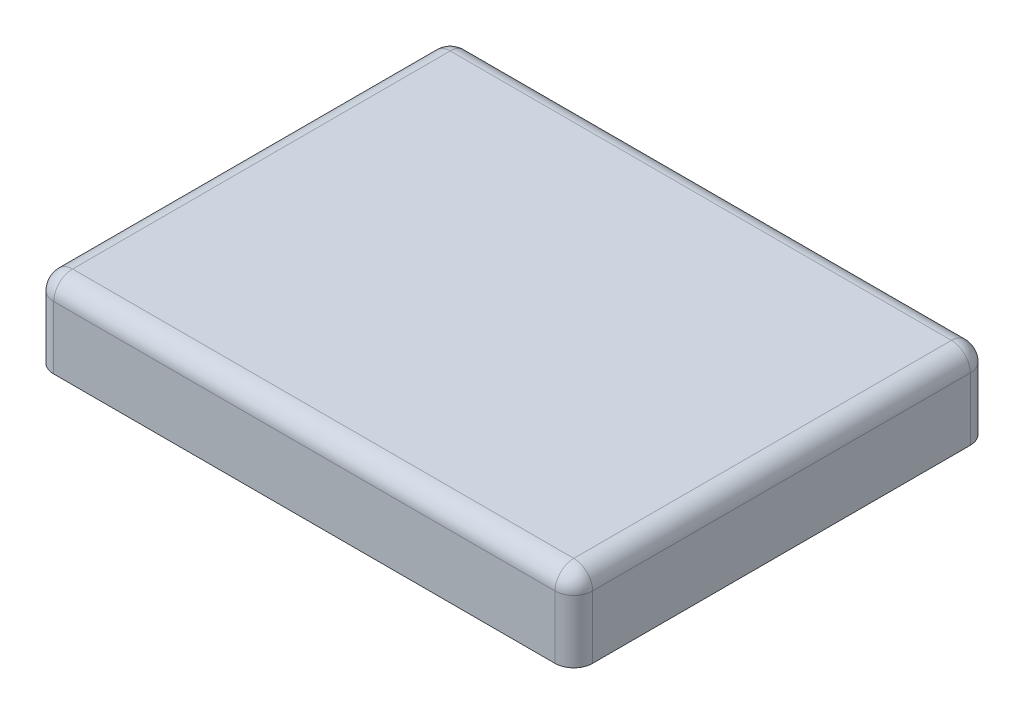
from build123d import *

# Parameters (mm, degrees)
SKETCH1_W           = 436.372
SKETCH1_H           = 336.296
BOSS_EXTRUDE1_DEPTH = 66.04
FILLET1_R           = 15.24


with BuildPart() as part:
    # Sketch1 → Boss-Extrude1 (new body)
    with BuildSketch(Plane(origin=(0, 0, 0), x_dir=(1, 0, 0), z_dir=(0, 1, 0))):
        with Locations((218.186, 168.148)):
            Rectangle(SKETCH1_W, SKETCH1_H)
    extrude(amount=BOSS_EXTRUDE1_DEPTH)

    # Fillet1
    fillet1_edges = [part.edges().sort_by_distance(p)[0] for p in [
        (436.372, 66.04, -168.148),
        (218.186, 66.04, -336.296),
        (0, 66.04, -168.148),
        (218.186, 66.04, 0),
        (0, 33.02, -336.296),
        (436.372, 33.02, -336.296),
        (436.372, 33.02, 0),
        (0, 33.02, 0),
    ]]
    fillet(fillet1_edges, radius=FILLET1_R)


solid = part.part
